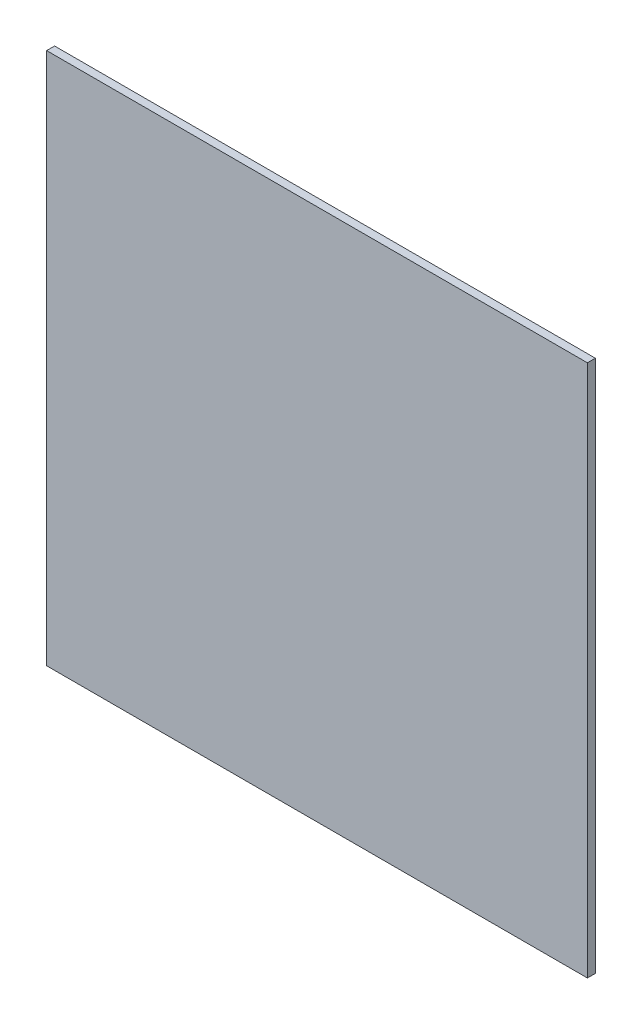
from build123d import *

# Parameters (mm, degrees)
ESQUISSE1_W        = 680
ESQUISSE1_H        = 670
BOSS_EXTRU_1_DEPTH = 10


with BuildPart() as part:
    # Esquisse1 → Boss.-Extru.1 (new body)
    with BuildSketch(Plane.XY):
        Rectangle(ESQUISSE1_W, ESQUISSE1_H)
    extrude(amount=BOSS_EXTRU_1_DEPTH)


solid = part.part
